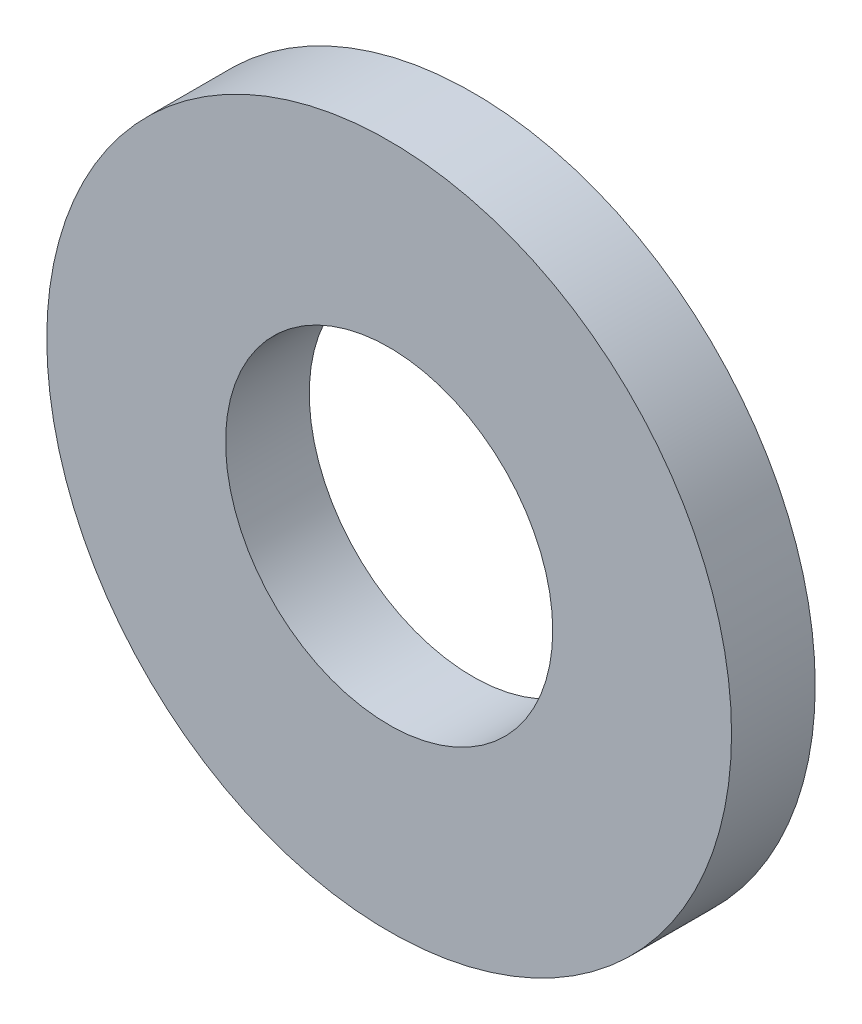
from build123d import *

# Parameters (mm, degrees)
SKETCH1_R           = 4.5
SKETCH1_R_2         = 2.15
BOSS_EXTRUDE1_DEPTH = 1.1


with BuildPart() as part:
    # Sketch1 → Boss-Extrude1 (new body)
    with BuildSketch(Plane.XY):
        Circle(SKETCH1_R)
        Circle(SKETCH1_R_2, mode=Mode.SUBTRACT)
    extrude(amount=BOSS_EXTRUDE1_DEPTH)


solid = part.part
